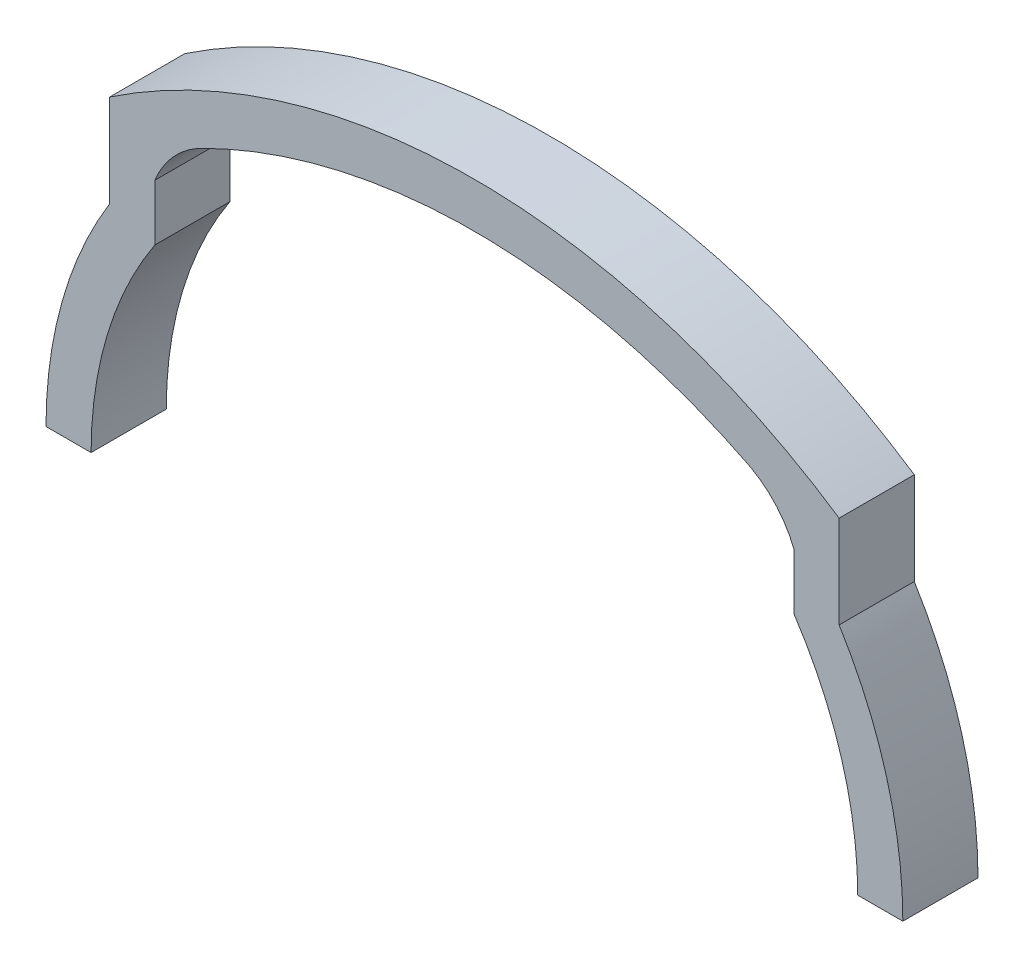
from build123d import *

# Parameters (mm, degrees)
BOSS_EXTRUDE2_DEPTH = 5


with BuildPart() as part:
    # Sketch1 → Boss-Extrude2 (new body)
    with BuildSketch(Plane.XY):
        with BuildLine():
            Line((-28.5, 0), (-25.5, 0))
            ThreePointArc((-25.5, 0), (-24.417654986, 7.350382643), (-21.2625, 14.076792737))
            Line((-21.2625, 14.076792737), (-21.2625, 17.80655265))
            ThreePointArc((-21.2625, 17.80655265), (-20.098232577, 19.704816367), (-18.361461142, 21.098569843))
            ThreePointArc((-18.361461142, 21.098569843), (0, 25.5), (18.361461142, 21.098569843))
            ThreePointArc((18.361461142, 21.098569843), (20.098232577, 19.704816367), (21.2625, 17.80655265))
            Line((21.2625, 17.80655265), (21.2625, 14.076792737))
            ThreePointArc((21.2625, 14.076792737), (24.417654986, 7.350382643), (25.5, 0))
            Line((25.5, 0), (28.5, 0))
            ThreePointArc((28.5, 0), (27.420168216, 7.770738382), (24.2625, 14.952628322))
            Line((24.2625, 14.952628322), (24.2625, 21.105139437))
            ThreePointArc((24.2625, 21.105139437), (0, 28.5), (-24.2625, 21.105139437))
            Line((-24.2625, 21.105139437), (-24.2625, 14.952628322))
            ThreePointArc((-24.2625, 14.952628322), (-27.420168216, 7.770738382), (-28.5, 0))
        make_face()
    extrude(amount=BOSS_EXTRUDE2_DEPTH)


solid = part.part
